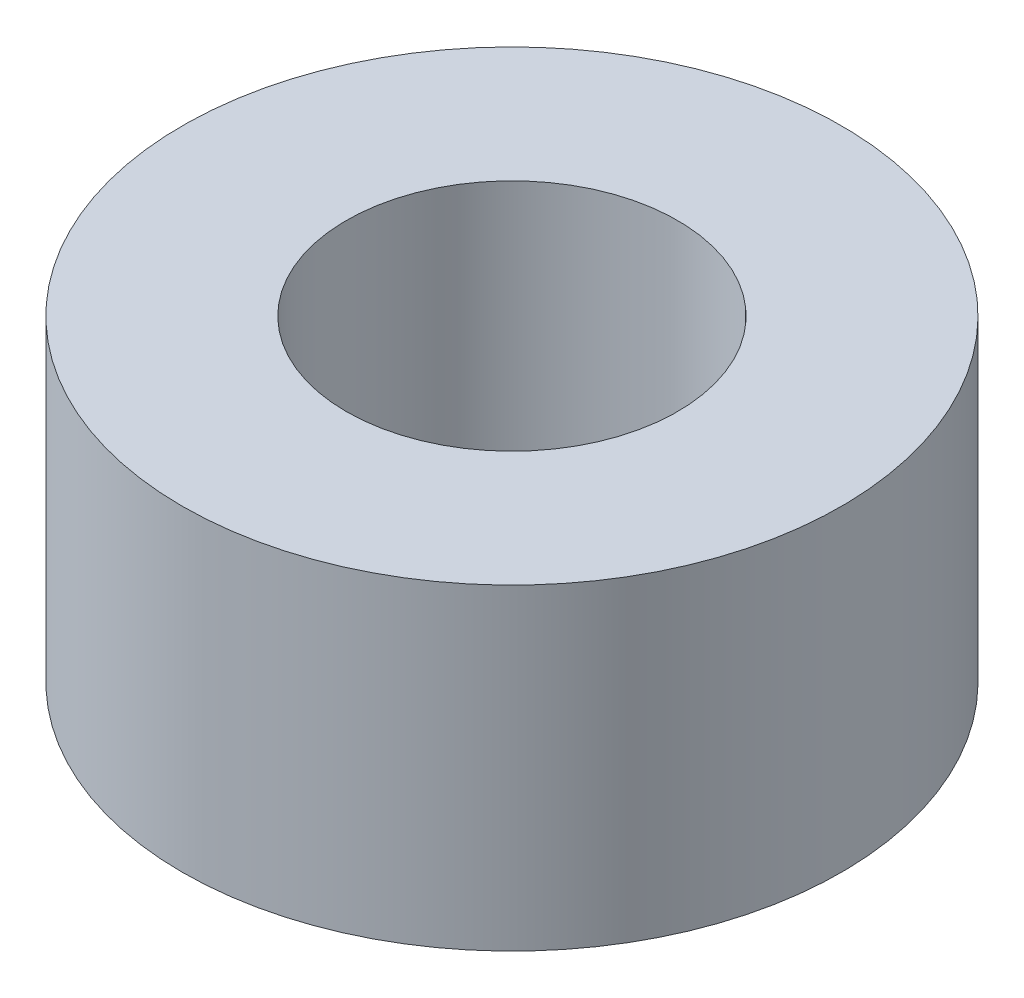
from build123d import *

# Parameters (mm, degrees)
SKETCH1_R           = 3.015
SKETCH1_R_2         = 1.515
BOSS_EXTRUDE1_DEPTH = 2.9


with BuildPart() as part:
    # Sketch1 → Boss-Extrude1 (new body)
    with BuildSketch(Plane(origin=(0, 0, 0), x_dir=(1, 0, 0), z_dir=(0, 1, 0))):
        Circle(SKETCH1_R)
        Circle(SKETCH1_R_2, mode=Mode.SUBTRACT)
    extrude(amount=BOSS_EXTRUDE1_DEPTH)


solid = part.part
